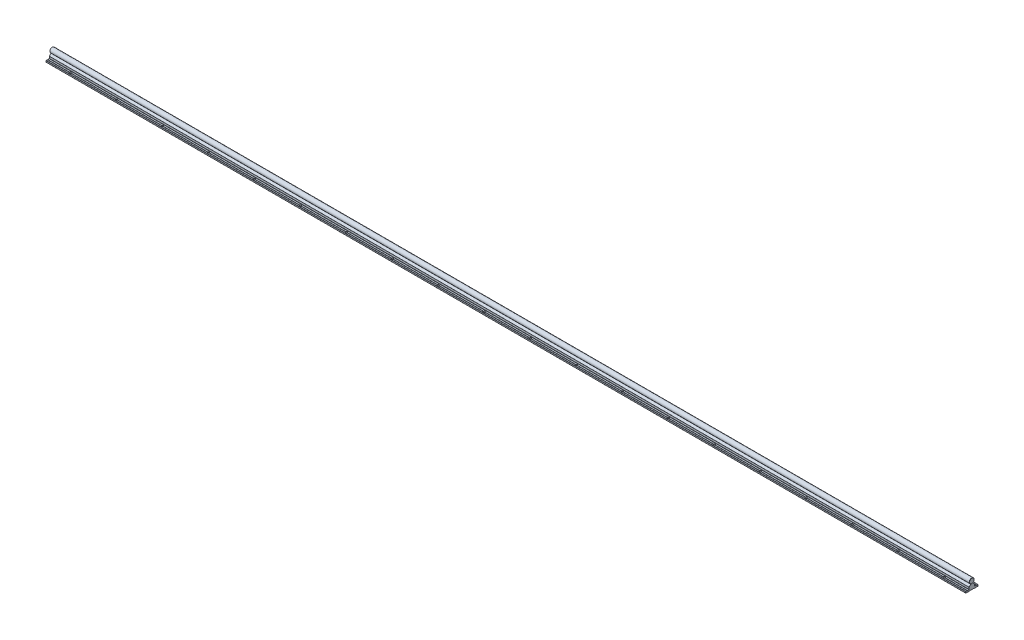
from build123d import *

# Parameters (mm, degrees)
EXTRUDE_10799_DEPTH    = 1500
SKETCH_1_3_R           = 8
EXTRUDE_10928_DEPTH    = 1500
FILLET_4_R             = 0.2
SKETCH_2_R             = 2.75
CUT_EXTRUDE_1_DEPTH    = 6
PATTERN_LINEAR_1_COUNT = 20
PATTERN_LINEAR_1_PITCH = 150
PATTERN_LINEAR_2_COUNT = 20
PATTERN_LINEAR_2_PITCH = 150
FILLET_1_R             = 0.3
CUT_EXTRUDE_2_DEPTH    = 3
FILLET_2_R             = 0.3
PATTERN_LINEAR_3_COUNT = 20
PATTERN_LINEAR_3_PITCH = 150
CHAMFER_1_SIZE         = 0.5
FILLET_3_R             = 0.5
FILLET_5_R             = 0.2
FILLET_6_R             = 0.1
FILLET_7_R             = 0.1


with BuildPart() as part:
    # Эскиз1 → Extrude 10799 (new body, symmetric)
    with BuildSketch(Plane(origin=(0, 0, 0), x_dir=(0, 0, -1), z_dir=(1, 0, 0))):
        Polygon((-20, -25), (-4.75, -25), (-4.75, -24.4), (4.75, -24.4), (4.75, -25), (20, -25), (20, -20), (15.5, -20), (15, -20.5), (14.5, -20), (9.25, -20), (9.25, -13.3), (9.110116754, -13.3), (4, -7.21), (3.8, -7.21), (2.309327437, -7.659439065), (0, -8.355703281), (-2.309327472, -7.659439054), (-3.8, -7.21), (-4, -7.21), (-9.110116754, -13.3), (-9.25, -13.3), (-9.25, -20), (-14.5, -20), (-15, -20.5), (-15.5, -20), (-20, -20), align=None)
    extrude(amount=EXTRUDE_10799_DEPTH, both=True)

    # Скругление4
    fillet_4_edges = [part.edges().sort_by_distance(p)[0] for p in [
        (0, -20, -15.5),
        (0, -24.4, -4.75),
        (0, -24.4, 4.75),
        (0, -20, 15.5),
        (0, -20, 14.5),
        (0, -8.355703281, 0),
        (0, -20, -14.5),
    ]]
    fillet(fillet_4_edges, radius=FILLET_4_R)

    # Эскиз2 → Вырез-Вытянуть1 (cut, through all)
    with BuildSketch(Plane(origin=(0, -20, 0), x_dir=(1, 0, 0), z_dir=(0, 1, 0))):
        with Locations((-1425, -15)):
            Circle(SKETCH_2_R)
        with Locations((-1425, 15)):
            Circle(SKETCH_2_R)
        with Locations((-1275, -15)):
            Circle(SKETCH_2_R)
        with Locations((-1275, 15)):
            Circle(SKETCH_2_R)
        with Locations((-1125, -15)):
            Circle(SKETCH_2_R)
        with Locations((-1125, 15)):
            Circle(SKETCH_2_R)
        with Locations((-975, -15)):
            Circle(SKETCH_2_R)
        with Locations((-975, 15)):
            Circle(SKETCH_2_R)
        with Locations((-825, -15)):
            Circle(SKETCH_2_R)
        with Locations((-825, 15)):
            Circle(SKETCH_2_R)
        with Locations((-675, -15)):
            Circle(SKETCH_2_R)
        with Locations((-675, 15)):
            Circle(SKETCH_2_R)
        with Locations((-525, -15)):
            Circle(SKETCH_2_R)
        with Locations((-525, 15)):
            Circle(SKETCH_2_R)
        with Locations((-375, -15)):
            Circle(SKETCH_2_R)
        with Locations((-375, 15)):
            Circle(SKETCH_2_R)
        with Locations((-225, -15)):
            Circle(SKETCH_2_R)
        with Locations((-225, 15)):
            Circle(SKETCH_2_R)
        with Locations((-75, -15)):
            Circle(SKETCH_2_R)
        with Locations((-75, 15)):
            Circle(SKETCH_2_R)
        with Locations((75, -15)):
            Circle(SKETCH_2_R)
        with Locations((75, 15)):
            Circle(SKETCH_2_R)
        with Locations((225, -15)):
            Circle(SKETCH_2_R)
        with Locations((225, 15)):
            Circle(SKETCH_2_R)
        with Locations((375, -15)):
            Circle(SKETCH_2_R)
        with Locations((375, 15)):
            Circle(SKETCH_2_R)
        with Locations((525, -15)):
            Circle(SKETCH_2_R)
        with Locations((525, 15)):
            Circle(SKETCH_2_R)
        with Locations((675, -15)):
            Circle(SKETCH_2_R)
        with Locations((675, 15)):
            Circle(SKETCH_2_R)
        with Locations((825, -15)):
            Circle(SKETCH_2_R)
        with Locations((825, 15)):
            Circle(SKETCH_2_R)
        with Locations((975, -15)):
            Circle(SKETCH_2_R)
        with Locations((975, 15)):
            Circle(SKETCH_2_R)
        with Locations((1125, -15)):
            Circle(SKETCH_2_R)
        with Locations((1125, 15)):
            Circle(SKETCH_2_R)
        with Locations((1275, -15)):
            Circle(SKETCH_2_R)
        with Locations((1275, 15)):
            Circle(SKETCH_2_R)
        with Locations((1425, -15)):
            Circle(SKETCH_2_R)
        with Locations((1425, 15)):
            Circle(SKETCH_2_R)
    extrude(amount=-CUT_EXTRUDE_1_DEPTH, mode=Mode.SUBTRACT)

    # Эскиз3 → Вырез-Повернуть1 (revolve, cut)
    with BuildSketch(Plane.XY):
        Polygon((-1425, 0), (-1427.2, -1.270170592), (-1427.2, -7.5), (-1427.75, -7.5), (-1427.75, -19), (-1429.75, -19), (-1429.75, -24.4), (-1425, -24.4), align=None)
    cut_revolve_1 = revolve(axis=Axis((-1425, 56.434869358, 0), (0, -1, 0)), mode=Mode.SUBTRACT)

    # Линейный массив1: Вырез-Повернуть1 ×20
    with Locations(*[(i * PATTERN_LINEAR_1_PITCH, 0, 0) for i in range(1, PATTERN_LINEAR_1_COUNT)]):
        add(cut_revolve_1, mode=Mode.SUBTRACT)

    # Скругление3
    fillet_3_edges = [part.edges().sort_by_distance(p)[0] for p in [
        (0, -20, -9.25),
        (0, -20, -20),
        (0, -25, -20),
        (0, -25, -4.75),
        (0, -25, 4.75),
        (0, -20, 9.25),
        (0, -25, 20),
        (0, -20, 20),
    ]]
    fillet(fillet_3_edges, radius=FILLET_3_R)

    # Скругление5
    fillet_5_edges = [part.edges().sort_by_distance(p)[0] for p in [
        (0, -7.21, 4),
        (0, -7.21, 3.8),
        (0, -7.21, -3.8),
        (0, -7.21, -4),
    ]]
    fillet(fillet_5_edges, radius=FILLET_5_R)

    # Скругление6
    fillet_6_edges = [part.edges().sort_by_distance(p)[0] for p in [
        (0, -13.3, 9.25),
        (0, -13.3, -9.25),
    ]]
    fillet(fillet_6_edges, radius=FILLET_6_R)

    # Скругление7
    fillet_7_edges = [part.edges().sort_by_distance(p)[0] for p in [
        (0, -13.3, 9.110116754),
        (0, -13.3, -9.110116754),
    ]]
    fillet(fillet_7_edges, radius=FILLET_7_R)


with BuildPart() as body_2:
    # Эскиз1<3> → Extrude 10928 (new body, symmetric)
    with BuildSketch(Plane(origin=(0, 0, 0), x_dir=(0, 0, -1), z_dir=(1, 0, 0))):
        Circle(SKETCH_1_3_R)
    extrude(amount=EXTRUDE_10928_DEPTH, both=True)

    # Эскиз4 → Вырез-Повернуть2 (revolve, cut)
    with BuildSketch(Plane.XY):
        Polygon((-1425, -10), (-1427.2, -10), (-1427.2, -1.270170592), (-1425, 0), align=None)
    cut_revolve_2 = revolve(axis=Axis((-1425, 39.840222878, 0), (0, -1, 0)), mode=Mode.SUBTRACT)

    # Линейный массив2: Вырез-Повернуть2 ×20
    with Locations(*[(i * PATTERN_LINEAR_2_PITCH, 0, 0) for i in range(1, PATTERN_LINEAR_2_COUNT)]):
        add(cut_revolve_2, mode=Mode.SUBTRACT)

    # Фаска1
    chamfer_1_edges = [body_2.edges().sort_by_distance(p)[0] for p in [
        (-1500, 0, 8),
        (1500, 0, 8),
    ]]
    chamfer(chamfer_1_edges, length=CHAMFER_1_SIZE)


with BuildPart() as body_3:
    # Эскиз5 → Повернуть1 (revolve)
    with BuildSketch(Plane.XY):
        Polygon((-1425, -24), (-1429.5, -24), (-1429.5, -19), (-1427.5, -19), (-1427.5, -2.461880215), (-1426.7, -2), (-1425, -2), align=None)
    revolve(axis=Axis((-1425, 35.529626596, 0), (0, -1, 0)))

    # Скругление1
    fillet_1_edges = [body_3.edges().sort_by_distance(p)[0] for p in [
        (-1420.5, -19, 0),
    ]]
    fillet(fillet_1_edges, radius=FILLET_1_R)

    # Эскиз6 → Вырез-Вытянуть2 (cut)
    with BuildSketch(Plane.XZ.offset(24)):
        Polygon((-1423.25, -1.010362971), (-1423.25, 1.010362971), (-1425, 2.020725942), (-1426.75, 1.010362971), (-1426.75, -1.010362971), (-1425, -2.020725942), align=None)
    extrude(amount=-CUT_EXTRUDE_2_DEPTH, mode=Mode.SUBTRACT)

    # Скругление2
    fillet_2_edges = [body_3.edges().sort_by_distance(p)[0] for p in [
        (-1424.125, -24, -1.515544457),
        (-1423.25, -24, 0),
        (-1424.125, -24, 1.515544457),
        (-1425.875, -24, 1.515544457),
        (-1426.75, -24, 0),
        (-1425.875, -24, -1.515544457),
        (-1420.5, -24, 0),
    ]]
    fillet(fillet_2_edges, radius=FILLET_2_R)


with BuildPart() as pattern_linear_3_1:
    # Линейный массив3: pattern copy
    add(body_3.part.moved(Location(Vector(1, 0, 0) * (1 * PATTERN_LINEAR_3_PITCH))))


with BuildPart() as pattern_linear_3_2:
    # Линейный массив3: pattern copy
    add(body_3.part.moved(Location(Vector(1, 0, 0) * (2 * PATTERN_LINEAR_3_PITCH))))


with BuildPart() as pattern_linear_3_3:
    # Линейный массив3: pattern copy
    add(body_3.part.moved(Location(Vector(1, 0, 0) * (3 * PATTERN_LINEAR_3_PITCH))))


with BuildPart() as pattern_linear_3_4:
    # Линейный массив3: pattern copy
    add(body_3.part.moved(Location(Vector(1, 0, 0) * (4 * PATTERN_LINEAR_3_PITCH))))


with BuildPart() as pattern_linear_3_5:
    # Линейный массив3: pattern copy
    add(body_3.part.moved(Location(Vector(1, 0, 0) * (5 * PATTERN_LINEAR_3_PITCH))))


with BuildPart() as pattern_linear_3_6:
    # Линейный массив3: pattern copy
    add(body_3.part.moved(Location(Vector(1, 0, 0) * (6 * PATTERN_LINEAR_3_PITCH))))


with BuildPart() as pattern_linear_3_7:
    # Линейный массив3: pattern copy
    add(body_3.part.moved(Location(Vector(1, 0, 0) * (7 * PATTERN_LINEAR_3_PITCH))))


with BuildPart() as pattern_linear_3_8:
    # Линейный массив3: pattern copy
    add(body_3.part.moved(Location(Vector(1, 0, 0) * (8 * PATTERN_LINEAR_3_PITCH))))


with BuildPart() as pattern_linear_3_9:
    # Линейный массив3: pattern copy
    add(body_3.part.moved(Location(Vector(1, 0, 0) * (9 * PATTERN_LINEAR_3_PITCH))))


with BuildPart() as pattern_linear_3_10:
    # Линейный массив3: pattern copy
    add(body_3.part.moved(Location(Vector(1, 0, 0) * (10 * PATTERN_LINEAR_3_PITCH))))


with BuildPart() as pattern_linear_3_11:
    # Линейный массив3: pattern copy
    add(body_3.part.moved(Location(Vector(1, 0, 0) * (11 * PATTERN_LINEAR_3_PITCH))))


with BuildPart() as pattern_linear_3_12:
    # Линейный массив3: pattern copy
    add(body_3.part.moved(Location(Vector(1, 0, 0) * (12 * PATTERN_LINEAR_3_PITCH))))


with BuildPart() as pattern_linear_3_13:
    # Линейный массив3: pattern copy
    add(body_3.part.moved(Location(Vector(1, 0, 0) * (13 * PATTERN_LINEAR_3_PITCH))))


with BuildPart() as pattern_linear_3_14:
    # Линейный массив3: pattern copy
    add(body_3.part.moved(Location(Vector(1, 0, 0) * (14 * PATTERN_LINEAR_3_PITCH))))


with BuildPart() as pattern_linear_3_15:
    # Линейный массив3: pattern copy
    add(body_3.part.moved(Location(Vector(1, 0, 0) * (15 * PATTERN_LINEAR_3_PITCH))))


with BuildPart() as pattern_linear_3_16:
    # Линейный массив3: pattern copy
    add(body_3.part.moved(Location(Vector(1, 0, 0) * (16 * PATTERN_LINEAR_3_PITCH))))


with BuildPart() as pattern_linear_3_17:
    # Линейный массив3: pattern copy
    add(body_3.part.moved(Location(Vector(1, 0, 0) * (17 * PATTERN_LINEAR_3_PITCH))))


with BuildPart() as pattern_linear_3_18:
    # Линейный массив3: pattern copy
    add(body_3.part.moved(Location(Vector(1, 0, 0) * (18 * PATTERN_LINEAR_3_PITCH))))


with BuildPart() as pattern_linear_3_19:
    # Линейный массив3: pattern copy
    add(body_3.part.moved(Location(Vector(1, 0, 0) * (19 * PATTERN_LINEAR_3_PITCH))))


solid = Compound([part.part, body_2.part, body_3.part, pattern_linear_3_1.part, pattern_linear_3_2.part, pattern_linear_3_3.part, pattern_linear_3_4.part, pattern_linear_3_5.part, pattern_linear_3_6.part, pattern_linear_3_7.part, pattern_linear_3_8.part, pattern_linear_3_9.part, pattern_linear_3_10.part, pattern_linear_3_11.part, pattern_linear_3_12.part, pattern_linear_3_13.part, pattern_linear_3_14.part, pattern_linear_3_15.part, pattern_linear_3_16.part, pattern_linear_3_17.part, pattern_linear_3_18.part, pattern_linear_3_19.part])
